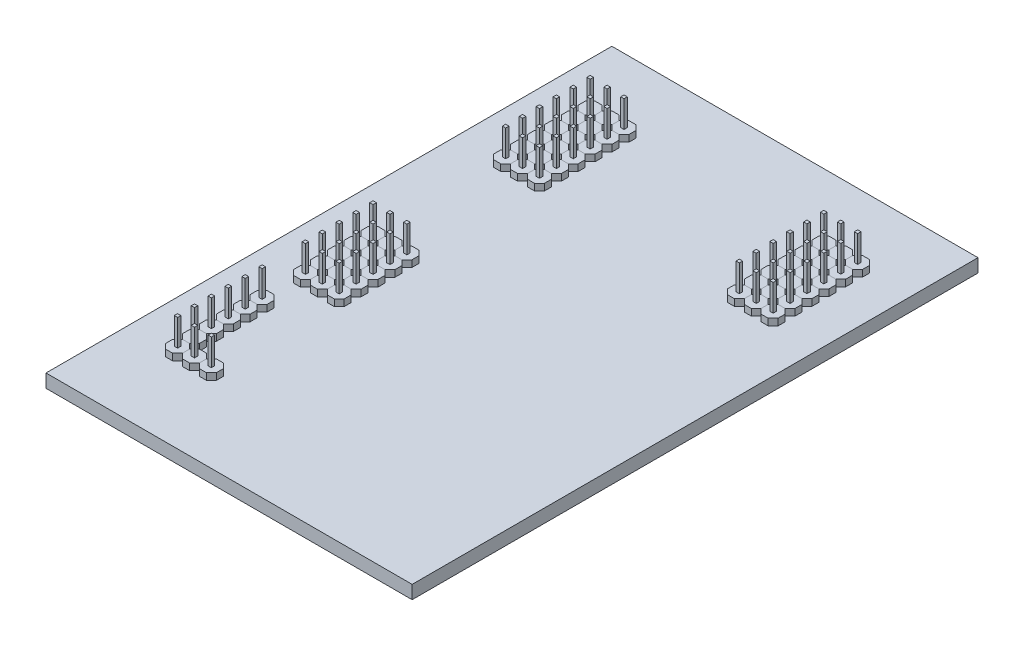
from build123d import *

# Parameters (mm, degrees)
SKICA1_W                = 55
SKICA1_H                = 85
P_IDAT_VYSUNUT_M1_DEPTH = 2
P_IDAT_VYSUNUT_M2_DEPTH = 1
SKICA3_W                = 0.5
SKICA3_H                = 0.5
P_IDAT_VYSUNUT_M3_DEPTH = 4
LINPOLE1_COUNT          = 6
LINPOLE1_PITCH          = 2.54
LINPOLE2_COUNT          = 3
LINPOLE2_PITCH          = 2.54
LINPOLE3_COUNT          = 2
LINPOLE3_PITCH          = 6.5
LINPOLE4_COUNT          = 3
LINPOLE4_PITCH          = 2.54
LINPOLE5_COUNT          = 5
LINPOLE5_PITCH          = 2.54
LINPOLE6_COUNT          = 2
LINPOLE6_PITCH          = 25
LINPOLE7_COUNT          = 2
LINPOLE7_PITCH          = 7.62


with BuildPart() as part:
    # Skica1 → Přidat vysunutím1 (new body)
    with BuildSketch(Plane(origin=(0, 0, 0), x_dir=(1, 0, 0), z_dir=(0, 1, 0))):
        Rectangle(SKICA1_W, SKICA1_H)
    extrude(amount=P_IDAT_VYSUNUT_M1_DEPTH)


with BuildPart() as body_2:
    # Skica2 → Přidat vysunutím2 (new body)
    with BuildSketch(Plane(origin=(0, 2, 0), x_dir=(1, 0, 0), z_dir=(0, 1, 0))):
        Polygon((-19.563989583, -16.173931122), (-20.616090831, -16.173931122), (-21.360038757, -16.917879048), (-21.360038757, -17.969980296), (-20.616090831, -18.713928223), (-19.563989583, -18.713928223), (-18.820041656, -17.969980296), (-18.820041656, -16.917879048), align=None)
    extrude(amount=P_IDAT_VYSUNUT_M2_DEPTH)

    # Skica3 → Přidat vysunutím3 (add)
    with BuildSketch(Plane(origin=(0, 3, 0), x_dir=(1, 0, 0), z_dir=(0, 1, 0))):
        with Locations((-20.090040207, -17.443929672)):
            Rectangle(SKICA3_W, SKICA3_H)
    extrude(amount=P_IDAT_VYSUNUT_M3_DEPTH)


with BuildPart() as linpole1_1:
    # LinPole1: pattern copy
    add(body_2.part.moved(Location(Vector(0, 0, 1) * (1 * LINPOLE1_PITCH))))


with BuildPart() as linpole1_2:
    # LinPole1: pattern copy
    add(body_2.part.moved(Location(Vector(0, 0, 1) * (2 * LINPOLE1_PITCH))))


with BuildPart() as linpole1_3:
    # LinPole1: pattern copy
    add(body_2.part.moved(Location(Vector(0, 0, 1) * (3 * LINPOLE1_PITCH))))


with BuildPart() as linpole1_4:
    # LinPole1: pattern copy
    add(body_2.part.moved(Location(Vector(0, 0, 1) * (4 * LINPOLE1_PITCH))))


with BuildPart() as linpole1_5:
    # LinPole1: pattern copy
    add(body_2.part.moved(Location(Vector(0, 0, 1) * (5 * LINPOLE1_PITCH))))


with BuildPart() as linpole2_1:
    # LinPole2: pattern copy
    add(linpole1_5.part.moved(Location(Vector(1, 0, 0) * (1 * LINPOLE2_PITCH))))


with BuildPart() as linpole2_2:
    # LinPole2: pattern copy
    add(linpole1_5.part.moved(Location(Vector(1, 0, 0) * (2 * LINPOLE2_PITCH))))


with BuildPart() as linpole3_1:
    # LinPole3: pattern copy
    add(body_2.part.moved(Location(Vector(0, 0, -1) * (1 * LINPOLE3_PITCH))))


with BuildPart() as linpole4_1:
    # LinPole4: pattern copy
    add(linpole3_1.part.moved(Location(Vector(1, 0, 0) * (1 * LINPOLE4_PITCH))))


with BuildPart() as linpole4_2:
    # LinPole4: pattern copy
    add(linpole3_1.part.moved(Location(Vector(1, 0, 0) * (2 * LINPOLE4_PITCH))))


with BuildPart() as linpole5_1:
    # LinPole5: pattern copy
    add(linpole3_1.part.moved(Location(Vector(0, 0, -1) * (1 * LINPOLE5_PITCH))))


with BuildPart() as linpole5_2:
    # LinPole5: pattern copy
    add(linpole3_1.part.moved(Location(Vector(0, 0, -1) * (2 * LINPOLE5_PITCH))))


with BuildPart() as linpole5_3:
    # LinPole5: pattern copy
    add(linpole3_1.part.moved(Location(Vector(0, 0, -1) * (3 * LINPOLE5_PITCH))))


with BuildPart() as linpole5_4:
    # LinPole5: pattern copy
    add(linpole3_1.part.moved(Location(Vector(0, 0, -1) * (4 * LINPOLE5_PITCH))))


with BuildPart() as linpole5_5:
    # LinPole5: pattern copy
    add(linpole4_1.part.moved(Location(Vector(0, 0, -1) * (1 * LINPOLE5_PITCH))))


with BuildPart() as linpole5_6:
    # LinPole5: pattern copy
    add(linpole4_1.part.moved(Location(Vector(0, 0, -1) * (2 * LINPOLE5_PITCH))))


with BuildPart() as linpole5_7:
    # LinPole5: pattern copy
    add(linpole4_1.part.moved(Location(Vector(0, 0, -1) * (3 * LINPOLE5_PITCH))))


with BuildPart() as linpole5_8:
    # LinPole5: pattern copy
    add(linpole4_1.part.moved(Location(Vector(0, 0, -1) * (4 * LINPOLE5_PITCH))))


with BuildPart() as linpole5_9:
    # LinPole5: pattern copy
    add(linpole4_2.part.moved(Location(Vector(0, 0, -1) * (1 * LINPOLE5_PITCH))))


with BuildPart() as linpole5_10:
    # LinPole5: pattern copy
    add(linpole4_2.part.moved(Location(Vector(0, 0, -1) * (2 * LINPOLE5_PITCH))))


with BuildPart() as linpole5_11:
    # LinPole5: pattern copy
    add(linpole4_2.part.moved(Location(Vector(0, 0, -1) * (3 * LINPOLE5_PITCH))))


with BuildPart() as linpole5_12:
    # LinPole5: pattern copy
    add(linpole4_2.part.moved(Location(Vector(0, 0, -1) * (4 * LINPOLE5_PITCH))))


with BuildPart() as linpole6_1:
    # LinPole6: pattern copy
    add(linpole5_10.part.moved(Location(Vector(0, 0, -1) * (1 * LINPOLE6_PITCH))))


with BuildPart() as linpole6_2:
    # LinPole6: pattern copy
    add(linpole5_6.part.moved(Location(Vector(0, 0, -1) * (1 * LINPOLE6_PITCH))))


with BuildPart() as linpole6_3:
    # LinPole6: pattern copy
    add(linpole5_2.part.moved(Location(Vector(0, 0, -1) * (1 * LINPOLE6_PITCH))))


with BuildPart() as linpole6_4:
    # LinPole6: pattern copy
    add(linpole5_3.part.moved(Location(Vector(0, 0, -1) * (1 * LINPOLE6_PITCH))))


with BuildPart() as linpole6_5:
    # LinPole6: pattern copy
    add(linpole5_7.part.moved(Location(Vector(0, 0, -1) * (1 * LINPOLE6_PITCH))))


with BuildPart() as linpole6_6:
    # LinPole6: pattern copy
    add(linpole5_8.part.moved(Location(Vector(0, 0, -1) * (1 * LINPOLE6_PITCH))))


with BuildPart() as linpole6_7:
    # LinPole6: pattern copy
    add(linpole5_4.part.moved(Location(Vector(0, 0, -1) * (1 * LINPOLE6_PITCH))))


with BuildPart() as linpole6_8:
    # LinPole6: pattern copy
    add(linpole5_11.part.moved(Location(Vector(0, 0, -1) * (1 * LINPOLE6_PITCH))))


with BuildPart() as linpole6_9:
    # LinPole6: pattern copy
    add(linpole5_12.part.moved(Location(Vector(0, 0, -1) * (1 * LINPOLE6_PITCH))))


with BuildPart() as linpole7_1:
    # LinPole7: pattern copy
    add(linpole6_3.part.moved(Location(Vector(0, 0, -1) * (1 * LINPOLE7_PITCH))))


with BuildPart() as linpole7_2:
    # LinPole7: pattern copy
    add(linpole6_2.part.moved(Location(Vector(0, 0, -1) * (1 * LINPOLE7_PITCH))))


with BuildPart() as linpole7_3:
    # LinPole7: pattern copy
    add(linpole6_1.part.moved(Location(Vector(0, 0, -1) * (1 * LINPOLE7_PITCH))))


with BuildPart() as linpole7_4:
    # LinPole7: pattern copy
    add(linpole6_8.part.moved(Location(Vector(0, 0, -1) * (1 * LINPOLE7_PITCH))))


with BuildPart() as linpole7_5:
    # LinPole7: pattern copy
    add(linpole6_5.part.moved(Location(Vector(0, 0, -1) * (1 * LINPOLE7_PITCH))))


with BuildPart() as linpole7_6:
    # LinPole7: pattern copy
    add(linpole6_4.part.moved(Location(Vector(0, 0, -1) * (1 * LINPOLE7_PITCH))))


with BuildPart() as linpole7_7:
    # LinPole7: pattern copy
    add(linpole6_7.part.moved(Location(Vector(0, 0, -1) * (1 * LINPOLE7_PITCH))))


with BuildPart() as linpole7_8:
    # LinPole7: pattern copy
    add(linpole6_6.part.moved(Location(Vector(0, 0, -1) * (1 * LINPOLE7_PITCH))))


with BuildPart() as linpole7_9:
    # LinPole7: pattern copy
    add(linpole6_9.part.moved(Location(Vector(0, 0, -1) * (1 * LINPOLE7_PITCH))))


with BuildPart() as body_43:
    # Zrcadlit1: mirrored copy
    add(linpole6_9.part.mirror(Plane(origin=(0, 0, 0), x_dir=(0, 0, 1), z_dir=(1, 0, 0))))


with BuildPart() as body_44:
    # Zrcadlit1 2: mirrored copy
    add(linpole6_2.part.mirror(Plane(origin=(0, 0, 0), x_dir=(0, 0, 1), z_dir=(1, 0, 0))))


with BuildPart() as body_45:
    # Zrcadlit1 3: mirrored copy
    add(linpole7_6.part.mirror(Plane(origin=(0, 0, 0), x_dir=(0, 0, 1), z_dir=(1, 0, 0))))


with BuildPart() as body_46:
    # Zrcadlit1 4: mirrored copy
    add(linpole6_8.part.mirror(Plane(origin=(0, 0, 0), x_dir=(0, 0, 1), z_dir=(1, 0, 0))))


with BuildPart() as body_47:
    # Zrcadlit1 5: mirrored copy
    add(linpole6_1.part.mirror(Plane(origin=(0, 0, 0), x_dir=(0, 0, 1), z_dir=(1, 0, 0))))


with BuildPart() as body_48:
    # Zrcadlit1 6: mirrored copy
    add(linpole7_5.part.mirror(Plane(origin=(0, 0, 0), x_dir=(0, 0, 1), z_dir=(1, 0, 0))))


with BuildPart() as body_49:
    # Zrcadlit1 7: mirrored copy
    add(linpole6_7.part.mirror(Plane(origin=(0, 0, 0), x_dir=(0, 0, 1), z_dir=(1, 0, 0))))


with BuildPart() as body_50:
    # Zrcadlit1 8: mirrored copy
    add(linpole7_4.part.mirror(Plane(origin=(0, 0, 0), x_dir=(0, 0, 1), z_dir=(1, 0, 0))))


with BuildPart() as body_51:
    # Zrcadlit1 9: mirrored copy
    add(linpole6_6.part.mirror(Plane(origin=(0, 0, 0), x_dir=(0, 0, 1), z_dir=(1, 0, 0))))


with BuildPart() as body_52:
    # Zrcadlit1 10: mirrored copy
    add(linpole7_3.part.mirror(Plane(origin=(0, 0, 0), x_dir=(0, 0, 1), z_dir=(1, 0, 0))))


with BuildPart() as body_53:
    # Zrcadlit1 11: mirrored copy
    add(linpole6_5.part.mirror(Plane(origin=(0, 0, 0), x_dir=(0, 0, 1), z_dir=(1, 0, 0))))


with BuildPart() as body_54:
    # Zrcadlit1 12: mirrored copy
    add(linpole7_9.part.mirror(Plane(origin=(0, 0, 0), x_dir=(0, 0, 1), z_dir=(1, 0, 0))))


with BuildPart() as body_55:
    # Zrcadlit1 13: mirrored copy
    add(linpole7_2.part.mirror(Plane(origin=(0, 0, 0), x_dir=(0, 0, 1), z_dir=(1, 0, 0))))


with BuildPart() as body_56:
    # Zrcadlit1 14: mirrored copy
    add(linpole6_4.part.mirror(Plane(origin=(0, 0, 0), x_dir=(0, 0, 1), z_dir=(1, 0, 0))))


with BuildPart() as body_57:
    # Zrcadlit1 15: mirrored copy
    add(linpole7_8.part.mirror(Plane(origin=(0, 0, 0), x_dir=(0, 0, 1), z_dir=(1, 0, 0))))


with BuildPart() as body_58:
    # Zrcadlit1 16: mirrored copy
    add(linpole7_1.part.mirror(Plane(origin=(0, 0, 0), x_dir=(0, 0, 1), z_dir=(1, 0, 0))))


with BuildPart() as body_59:
    # Zrcadlit1 17: mirrored copy
    add(linpole6_3.part.mirror(Plane(origin=(0, 0, 0), x_dir=(0, 0, 1), z_dir=(1, 0, 0))))


with BuildPart() as body_60:
    # Zrcadlit1 18: mirrored copy
    add(linpole7_7.part.mirror(Plane(origin=(0, 0, 0), x_dir=(0, 0, 1), z_dir=(1, 0, 0))))


solid = Compound([part.part, body_2.part, linpole1_1.part, linpole1_2.part, linpole1_3.part, linpole1_4.part, linpole1_5.part, linpole2_1.part, linpole2_2.part, linpole3_1.part, linpole4_1.part, linpole4_2.part, linpole5_1.part, linpole5_2.part, linpole5_3.part, linpole5_4.part, linpole5_5.part, linpole5_6.part, linpole5_7.part, linpole5_8.part, linpole5_9.part, linpole5_10.part, linpole5_11.part, linpole5_12.part, linpole6_1.part, linpole6_2.part, linpole6_3.part, linpole6_4.part, linpole6_5.part, linpole6_6.part, linpole6_7.part, linpole6_8.part, linpole6_9.part, linpole7_1.part, linpole7_2.part, linpole7_3.part, linpole7_4.part, linpole7_5.part, linpole7_6.part, linpole7_7.part, linpole7_8.part, linpole7_9.part, body_43.part, body_44.part, body_45.part, body_46.part, body_47.part, body_48.part, body_49.part, body_50.part, body_51.part, body_52.part, body_53.part, body_54.part, body_55.part, body_56.part, body_57.part, body_58.part, body_59.part, body_60.part])
